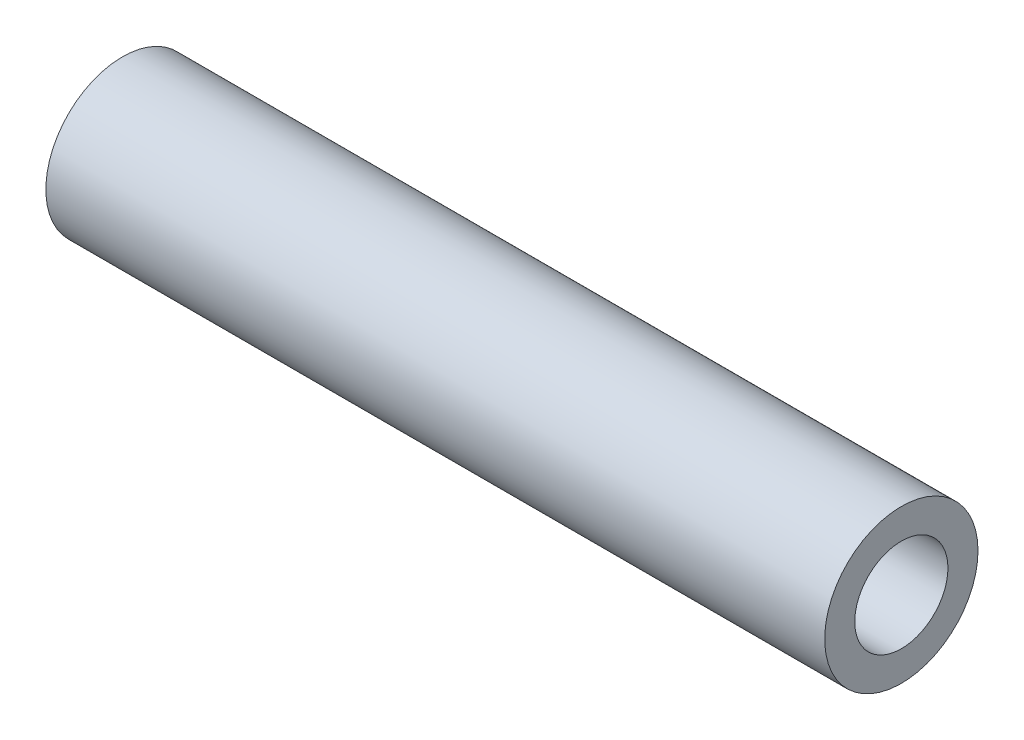
from build123d import *

# Parameters (mm, degrees)
SKETCH1_R           = 3.175
SKETCH1_R_2         = 1.9304
BOSS_EXTRUDE1_DEPTH = 16.129


with BuildPart() as part:
    # Sketch1 → Boss-Extrude1 (new body, symmetric)
    with BuildSketch(Plane(origin=(0, 0, 0), x_dir=(0, 0, -1), z_dir=(1, 0, 0))):
        Circle(SKETCH1_R)
        Circle(SKETCH1_R_2, mode=Mode.SUBTRACT)
    extrude(amount=BOSS_EXTRUDE1_DEPTH, both=True)


solid = part.part
